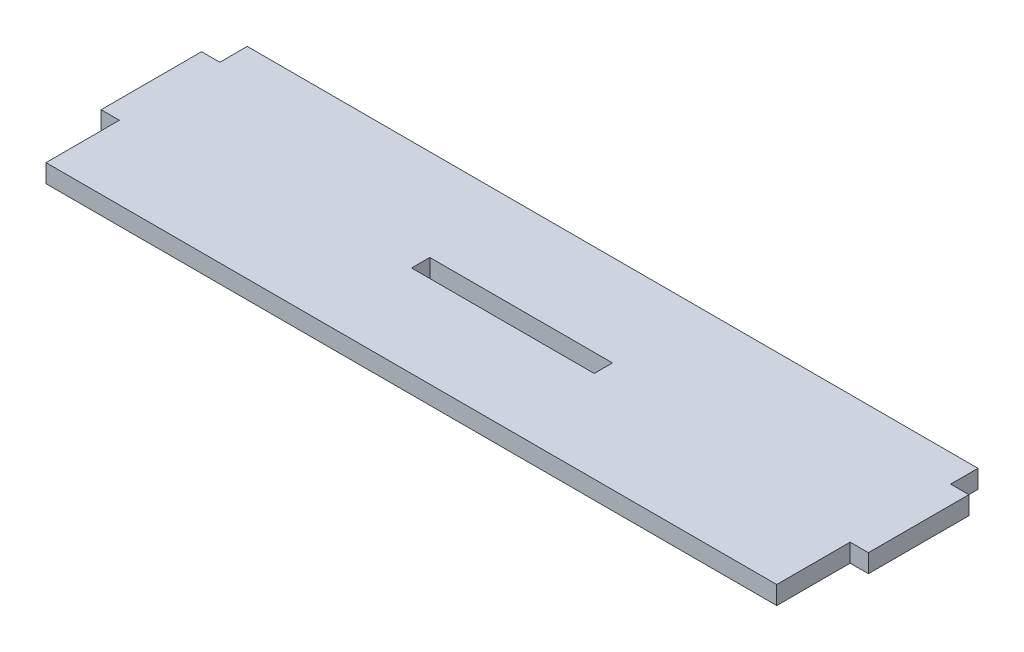
from build123d import *

# Parameters (mm, degrees)
SKETCH2_W           = 40
SKETCH2_H           = 4
BOSS_EXTRUDE1_DEPTH = 4


with BuildPart() as part:
    # Sketch2 → Boss-Extrude1 (new body)
    with BuildSketch(Plane(origin=(0, 0, 0), x_dir=(1, 0, 0), z_dir=(0, 1, 0))):
        Polygon((0, -6), (-4, -6), (-4, -28), (0, -28), (0, -44.07), (160, -44.07), (160, -28), (164, -28), (164, -6), (160, -6), (160, 0), (0, 0), align=None)
        with Locations((80, -22.035)):
            Rectangle(SKETCH2_W, SKETCH2_H, mode=Mode.SUBTRACT)
    extrude(amount=BOSS_EXTRUDE1_DEPTH)


solid = part.part
